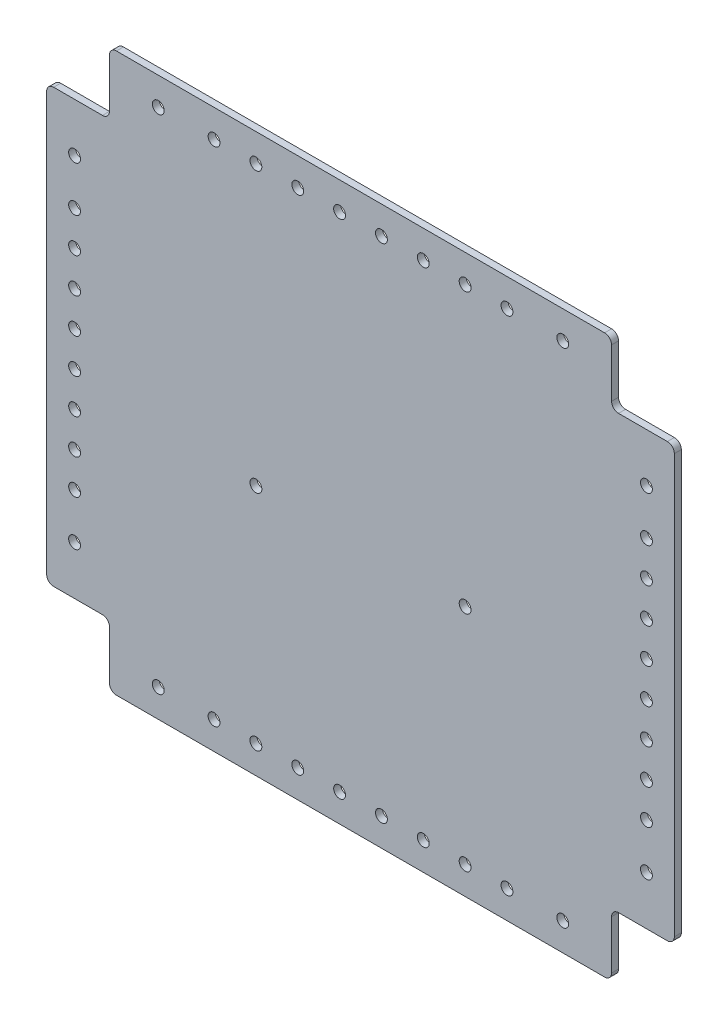
from build123d import *

# Parameters (mm, degrees)
SKETCH_1_W          = 450
SKETCH_1_H          = 400
EXTRUDE_1_DEPTH     = 5
SKETCH_3_R          = 3.75
SKETCH_3_R_2        = 4.25
CUT_EXTRUDE_2_DEPTH = 50
SKETCH_5_W          = 45
SKETCH_5_H          = 45
CUT_EXTRUDE_4_DEPTH = 56
FILLET_1_R          = 5
SKETCH_6_R          = 4.25
CUT_EXTRUDE_5_DEPTH = 90
SKETCH_7_R          = 4.25
CUT_EXTRUDE_6_DEPTH = 90


with BuildPart() as part:
    # 草图1 → 凸台-拉伸1 (new body)
    with BuildSketch(Plane.XY):
        Rectangle(SKETCH_1_W, SKETCH_1_H)
    extrude(amount=EXTRUDE_1_DEPTH)

    # 草图3 → 切除-拉伸2 (cut)
    with BuildSketch(Plane.XY.offset(5)):
        with Locations((205, -180)):
            Circle(SKETCH_3_R)
        with Locations((205, -120)):
            Circle(SKETCH_3_R_2)
        with Locations((145, -180)):
            Circle(SKETCH_3_R_2)
        with Locations((145, 180)):
            Circle(SKETCH_3_R_2)
        with Locations((205, 120)):
            Circle(SKETCH_3_R_2)
        with Locations((205, 180)):
            Circle(SKETCH_3_R)
        with Locations((-205, 180)):
            Circle(SKETCH_3_R)
        with Locations((-205, 120)):
            Circle(SKETCH_3_R_2)
        with Locations((-145, 180)):
            Circle(SKETCH_3_R_2)
        with Locations((-145, -180)):
            Circle(SKETCH_3_R_2)
        with Locations((-205, -120)):
            Circle(SKETCH_3_R_2)
        with Locations((-205, -180)):
            Circle(SKETCH_3_R)
    extrude(amount=-CUT_EXTRUDE_2_DEPTH, mode=Mode.SUBTRACT)

    # 草图5 → 切除-拉伸4 (cut)
    with BuildSketch(Plane.XY.offset(5)):
        with Locations((202.5, -177.5)):
            Rectangle(SKETCH_5_W, SKETCH_5_H)
        with Locations((-202.5, -177.5)):
            Rectangle(SKETCH_5_W, SKETCH_5_H)
        with Locations((-202.5, 177.5)):
            Rectangle(SKETCH_5_W, SKETCH_5_H)
        with Locations((202.5, 177.5)):
            Rectangle(SKETCH_5_W, SKETCH_5_H)
    extrude(amount=-CUT_EXTRUDE_4_DEPTH, mode=Mode.SUBTRACT)

    # 圆角1
    fillet_1_edges = [part.edges().sort_by_distance(p)[0] for p in [
        (-180, -200, 2.5),
        (-225, -155, 2.5),
        (-180, -155, 2.5),
        (225, -155, 2.5),
        (180, -200, 2.5),
        (180, -155, 2.5),
        (180, 200, 2.5),
        (225, 155, 2.5),
        (180, 155, 2.5),
        (-225, 155, 2.5),
        (-180, 200, 2.5),
        (-180, 155, 2.5),
    ]]
    fillet(fillet_1_edges, radius=FILLET_1_R)

    # 草图6 → 切除-拉伸5 (cut)
    with BuildSketch(Plane(origin=(0, 0, 0), x_dir=(-1, 0, 0), z_dir=(0, 0, -1))):
        with Locations((75, -180)):
            Circle(SKETCH_6_R)
        with Locations((-75, -180)):
            Circle(SKETCH_6_R)
        with Locations((-75, -20)):
            Circle(SKETCH_6_R)
        with Locations((75, -20)):
            Circle(SKETCH_6_R)
    extrude(amount=-CUT_EXTRUDE_5_DEPTH, mode=Mode.SUBTRACT)

    # 草图7 → 切除-拉伸6 (cut)
    with BuildSketch(Plane(origin=(0, 0, 0), x_dir=(-1, 0, 0), z_dir=(0, 0, -1))):
        with Locations((-15, 180)):
            Circle(SKETCH_7_R)
        with Locations((-45, 180)):
            Circle(SKETCH_7_R)
        with Locations((-75, 180)):
            Circle(SKETCH_7_R)
        with Locations((-105, 180)):
            Circle(SKETCH_7_R)
        with Locations((-205, 12.5)):
            Circle(SKETCH_7_R)
        with Locations((-205, 37.5)):
            Circle(SKETCH_7_R)
        with Locations((-205, 62.5)):
            Circle(SKETCH_7_R)
        with Locations((-205, 87.5)):
            Circle(SKETCH_7_R)
        with Locations((-205, -87.5)):
            Circle(SKETCH_7_R)
        with Locations((-205, -62.5)):
            Circle(SKETCH_7_R)
        with Locations((-205, -37.5)):
            Circle(SKETCH_7_R)
        with Locations((-205, -12.5)):
            Circle(SKETCH_7_R)
        with Locations((205, -12.5)):
            Circle(SKETCH_7_R)
        with Locations((205, -37.5)):
            Circle(SKETCH_7_R)
        with Locations((205, -62.5)):
            Circle(SKETCH_7_R)
        with Locations((205, -87.5)):
            Circle(SKETCH_7_R)
        with Locations((205, 87.5)):
            Circle(SKETCH_7_R)
        with Locations((205, 62.5)):
            Circle(SKETCH_7_R)
        with Locations((205, 37.5)):
            Circle(SKETCH_7_R)
        with Locations((205, 12.5)):
            Circle(SKETCH_7_R)
        with Locations((105, 180)):
            Circle(SKETCH_7_R)
        with Locations((75, 180)):
            Circle(SKETCH_7_R)
        with Locations((45, 180)):
            Circle(SKETCH_7_R)
        with Locations((15, 180)):
            Circle(SKETCH_7_R)
        with Locations((15, -180)):
            Circle(SKETCH_7_R)
        with Locations((45, -180)):
            Circle(SKETCH_7_R)
        with Locations((75, -180)):
            Circle(SKETCH_7_R)
        with Locations((105, -180)):
            Circle(SKETCH_7_R)
        with Locations((-105, -180)):
            Circle(SKETCH_7_R)
        with Locations((-75, -180)):
            Circle(SKETCH_7_R)
        with Locations((-45, -180)):
            Circle(SKETCH_7_R)
        with Locations((-15, -180)):
            Circle(SKETCH_7_R)
    extrude(amount=-CUT_EXTRUDE_6_DEPTH, mode=Mode.SUBTRACT)


solid = part.part
